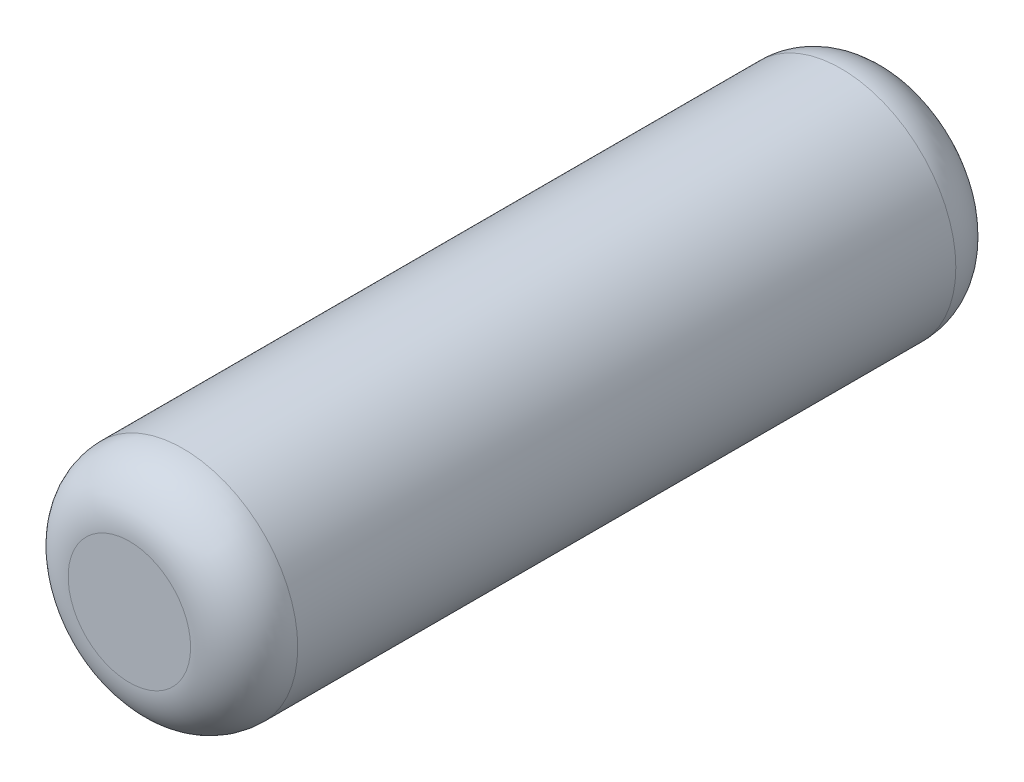
from build123d import *

# Parameters (mm, degrees)
SKETCH1_R           = 0.75
BOSS_EXTRUDE1_DEPTH = 2.5
FILLET1_R           = 0.35


with BuildPart() as part:
    # Sketch1 → Boss-Extrude1 (new body, symmetric)
    with BuildSketch(Plane.XY):
        Circle(SKETCH1_R)
    extrude(amount=BOSS_EXTRUDE1_DEPTH, both=True)

    # Fillet1
    fillet1_edges = [part.edges().sort_by_distance(p)[0] for p in [
        (-0.75, 0, -2.5),
        (-0.75, 0, 2.5),
    ]]
    fillet(fillet1_edges, radius=FILLET1_R)


solid = part.part
